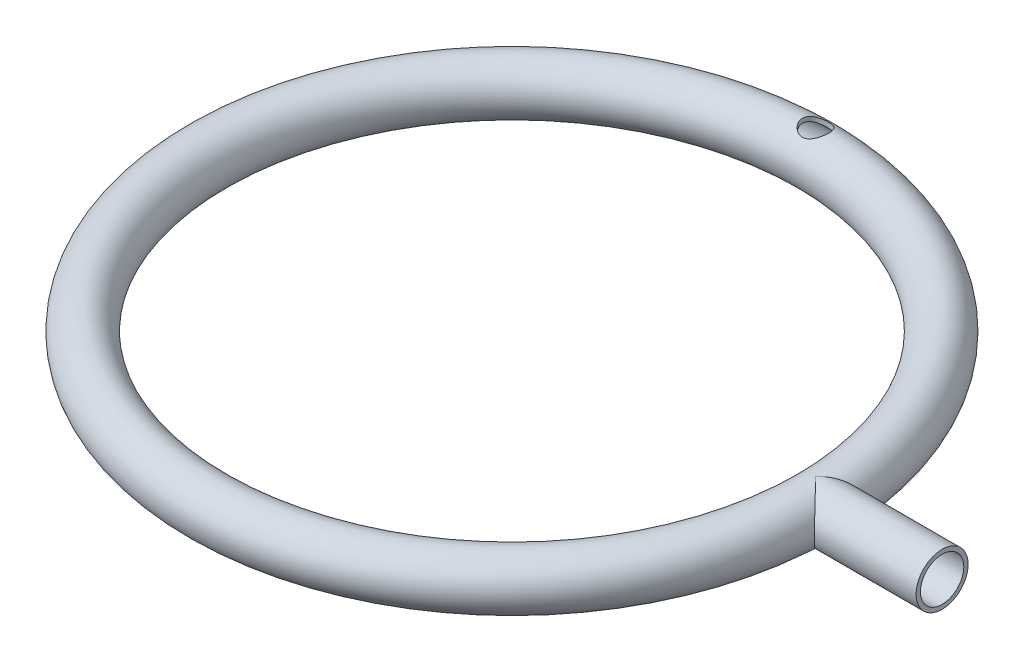
from build123d import *
from build123d.topology import SkipClean

# Parameters (mm, degrees)
SKETCH1_R           = 3.81
SKETCH1_R_2         = 3.175
SKETCH3_R           = 3.81
SKETCH3_R_2         = 3.175
BOSS_EXTRUDE1_DEPTH = 18.542
SKETCH4_R           = 3.175
CUT_EXTRUDE5_DEPTH  = 12.7
SKETCH5_R           = 1.905
CUT_EXTRUDE6_DEPTH  = 12.7


with BuildPart() as part:
    # Sketch1 → Revolve1 (revolve)
    with BuildSketch(Plane.XY, mode=Mode.PRIVATE) as revolve1_sk:
        with Locations((-44.45, 0)):
            Circle(SKETCH1_R)
        with Locations((-44.45, 0)):
            Circle(SKETCH1_R_2, mode=Mode.SUBTRACT)
    revolve(revolve1_sk.sketch.rotate(Axis((0, 0, 0), (0, 1, 0)), 270), axis=Axis((0, 0, 0), (0, 1, 0)))

    # Sketch3 → Boss-Extrude1 (add)
    with SkipClean():  # the faces are left unmerged after this step: merging them gives an invalid solid
        with BuildSketch(Plane(origin=(44.45, 0, 0), x_dir=(0, 0, -1), z_dir=(1, 0, 0))):
            with Locations(Location((0, 0, 0), (0, 0, 90))):
                Circle(SKETCH3_R)
            with Locations(Location((0, 0, 0), (0, 0, 275.057032313))):
                Circle(SKETCH3_R_2, mode=Mode.SUBTRACT)
        extrude(amount=BOSS_EXTRUDE1_DEPTH)

    # Sketch4 → Cut-Extrude5 (cut)
    with SkipClean():  # the faces are left unmerged after this step: merging them gives an invalid solid
        with BuildSketch(Plane(origin=(44.45, 0, 0), x_dir=(0, 0, -1), z_dir=(1, 0, 0))):
            with Locations(Location((0, 0, 0), (0, 0, 90))):
                Circle(SKETCH4_R)
        extrude(amount=CUT_EXTRUDE5_DEPTH, mode=Mode.SUBTRACT)

    # Sketch5 → Cut-Extrude6 (cut)
    with SkipClean():  # the faces are left unmerged after this step: merging them gives an invalid solid
        with BuildSketch(Plane(origin=(0, 0, 0), x_dir=(1, 0, 0), z_dir=(0, 1, 0))):
            with Locations(Location((0, 44.45, 0), (0, 0, 123.04107409))):
                Circle(SKETCH5_R)
        extrude(amount=CUT_EXTRUDE6_DEPTH, mode=Mode.SUBTRACT)


solid = part.part
